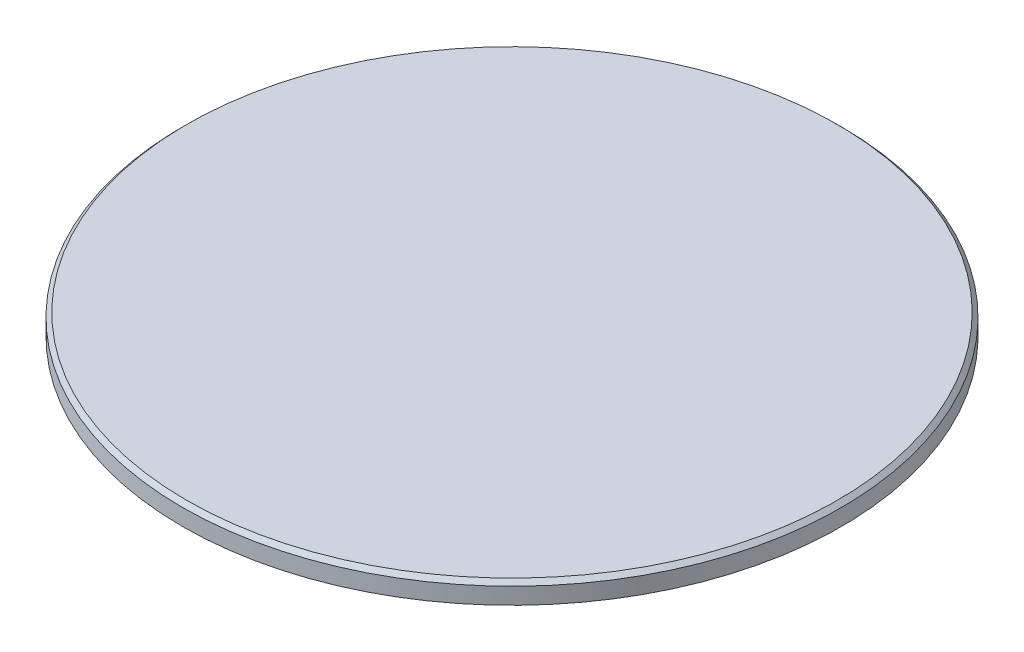
from build123d import *

# Parameters (mm, degrees)
SKETCH1_R           = 15.95
BOSS_EXTRUDE1_DEPTH = 1
CHAMFER1_SIZE       = 0.2


with BuildPart() as part:
    # Sketch1 → Boss-Extrude1 (new body)
    with BuildSketch(Plane(origin=(0, 0, 0), x_dir=(1, 0, 0), z_dir=(0, 1, 0))):
        Circle(SKETCH1_R)
    extrude(amount=BOSS_EXTRUDE1_DEPTH)

    # Chamfer1
    chamfer1_edges = [part.edges().sort_by_distance(p)[0] for p in [
        (-15.95, 1, 0),
    ]]
    chamfer(chamfer1_edges, length=CHAMFER1_SIZE)


solid = part.part
